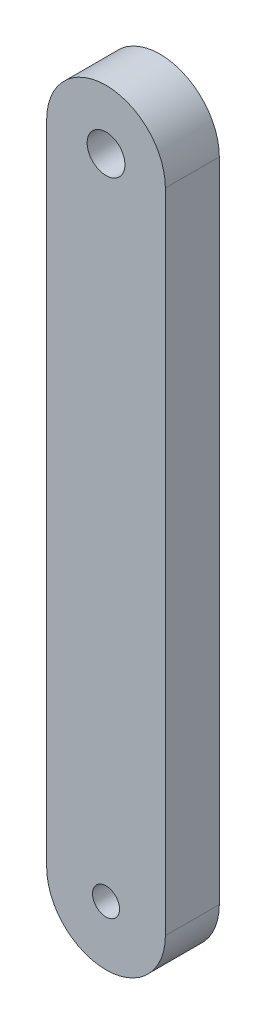
from build123d import *

# Parameters (mm, degrees)
SKETCH1_R           = 1.75
SKETCH1_R_2         = 1.25
BOSS_EXTRUDE2_DEPTH = 5


with BuildPart() as part:
    # Sketch1 → Boss-Extrude2 (new body)
    with BuildSketch(Plane.XY):
        with BuildLine():
            Line((376.409457729, 419.244133277), (376.409457729, 359.244133277))
            ThreePointArc((376.409457729, 359.244133277), (381.909457729, 353.744133277), (387.409457729, 359.244133277))
            Line((387.409457729, 359.244133277), (387.409457729, 419.244133277))
            ThreePointArc((387.409457729, 419.244133277), (381.909457729, 424.744133277), (376.409457729, 419.244133277))
        make_face()
        with Locations((381.909457729, 419.244133277)):
            Circle(SKETCH1_R, mode=Mode.SUBTRACT)
        with Locations((381.909457729, 359.244133277)):
            Circle(SKETCH1_R_2, mode=Mode.SUBTRACT)
    extrude(amount=BOSS_EXTRUDE2_DEPTH)


solid = part.part
